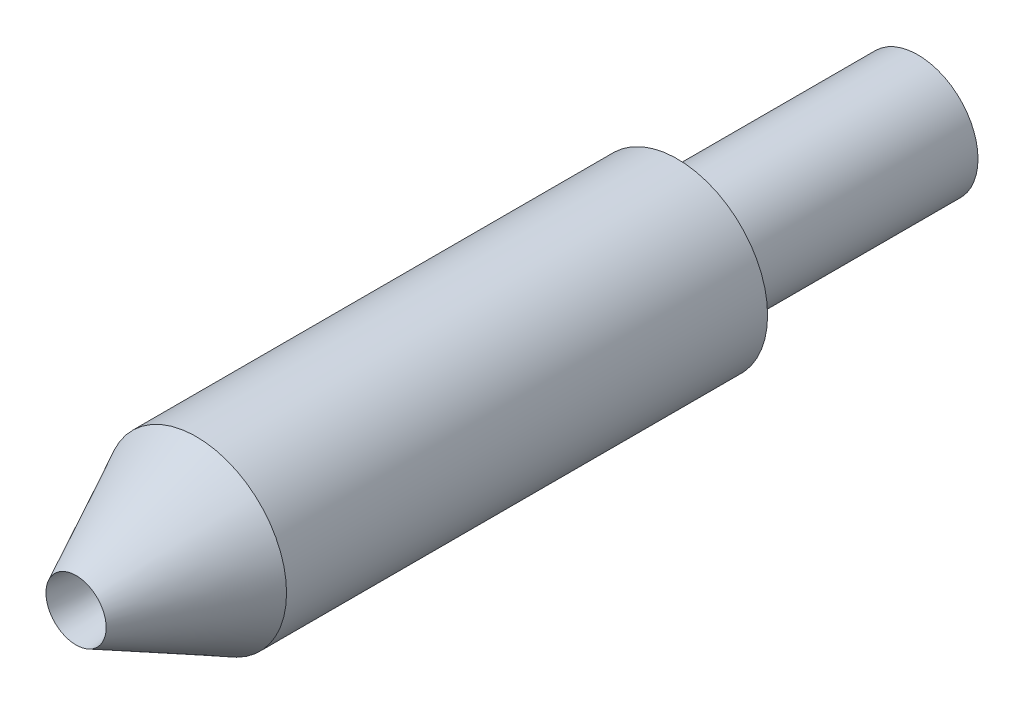
from build123d import *

# Parameters (mm, degrees)
SKETCH1_R           = 1.19126
BOSS_EXTRUDE1_DEPTH = 11.1125
SKETCH4_W           = 3.175
SKETCH4_H           = 0.39751
CUT_EXTRUDE1_START  = -2.38252
SKETCH6_R           = 0.39751
CUT_EXTRUDE1_DEPTH  = 11.1125


with BuildPart() as part:
    # Sketch1 → Boss-Extrude1 (new body)
    with BuildSketch(Plane.XY):
        Circle(SKETCH1_R)
    extrude(amount=-BOSS_EXTRUDE1_DEPTH)

    # Sketch2 → Cut-Revolve1 (revolve, cut)
    with BuildSketch(Plane(origin=(0, 0, 0), x_dir=(0, 0, -1), z_dir=(1, 0, 0))):
        Polygon((0, 0.39751), (1.5875, 1.19126), (0, 1.19126), align=None)
    revolve(axis=Axis((0, 0, 0), (0, 0, -1)), mode=Mode.SUBTRACT)

    # Sketch4 → Cut-Revolve2 (revolve, cut)
    with BuildSketch(Plane(origin=(0, 0, 0), x_dir=(0, 0, -1), z_dir=(1, 0, 0))):
        with Locations((9.525, 0.992505)):
            Rectangle(SKETCH4_W, SKETCH4_H)
    revolve(axis=Axis((0, 0, 0), (0, 0, -1)), mode=Mode.SUBTRACT)

    # Sketch5 → Cut-Revolve3 (revolve, cut)
    with BuildSketch(Plane(origin=(0, 0, 0), x_dir=(0, 0, -1), z_dir=(1, 0, 0))):
        Polygon((0, 0.39751), (1.5875, 0.19812), (1.5875, 0), (0, 0), align=None)
    revolve(axis=Axis((0, 0, 0), (0, 0, -1)), mode=Mode.SUBTRACT)

    # Sketch6 → Cut-Extrude1 (cut)
    with BuildSketch(Plane.XY.offset(CUT_EXTRUDE1_START)):
        Circle(SKETCH6_R)
    extrude(amount=-CUT_EXTRUDE1_DEPTH, mode=Mode.SUBTRACT)

    # Sketch7 → Cut-Revolve4 (revolve, cut)
    with BuildSketch(Plane(origin=(0, 0, 0), x_dir=(0, 0, -1), z_dir=(1, 0, 0))):
        Polygon((1.5875, 0.19812), (2.38252, 0.39751), (2.38252, 0), (1.5875, 0), align=None)
    revolve(axis=Axis((0, 0, 0), (0, 0, -1)), mode=Mode.SUBTRACT)


solid = part.part
